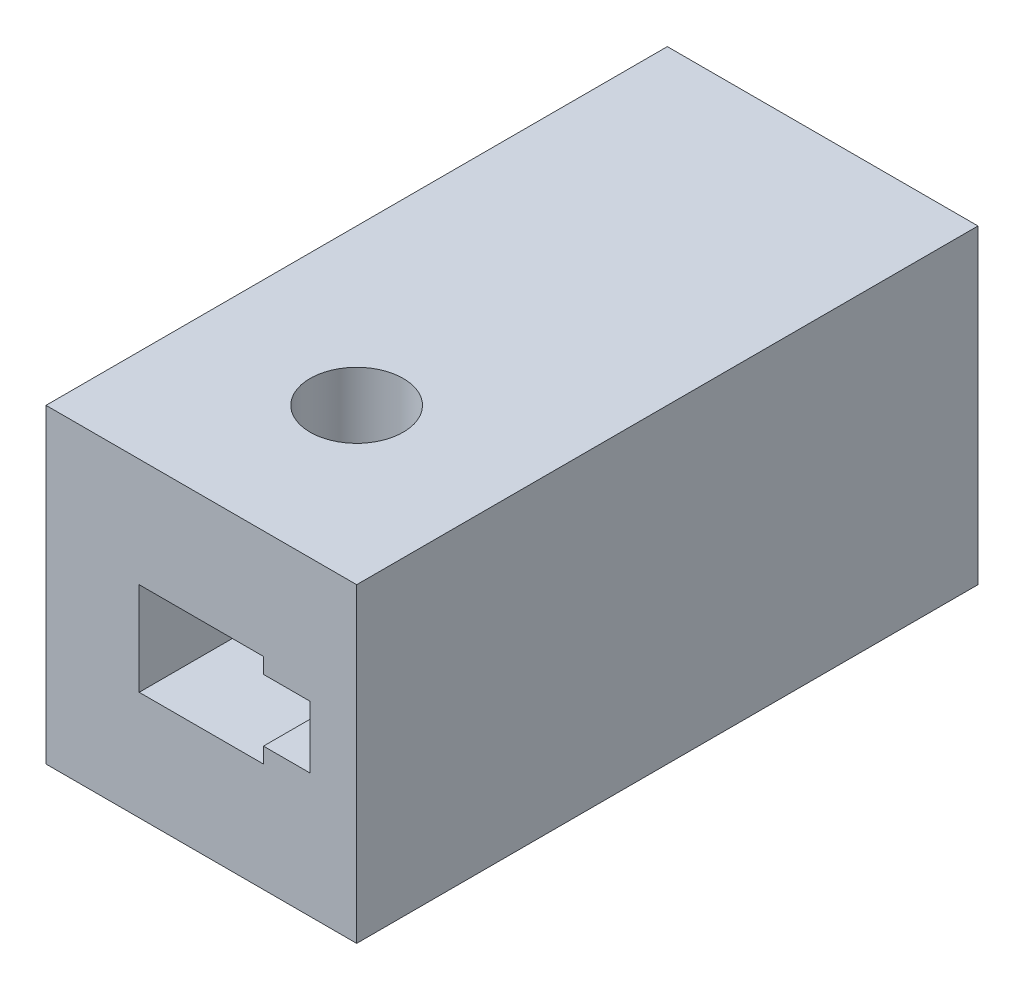
from build123d import *

# Parameters (mm, degrees)
SKETCH1_W           = 10
SKETCH1_H           = 10
BOSS_EXTRUDE1_DEPTH = 20
SKETCH2_R           = 1.5
CUT_EXTRUDE1_DEPTH  = 20


with BuildPart() as part:
    # Sketch1 → Boss-Extrude1 (new body)
    with BuildSketch(Plane.XY):
        Rectangle(SKETCH1_W, SKETCH1_H)
        Polygon((2, -1.5), (-2, -1.5), (-2, 1.5), (2, 1.5), (2, 1), (3.5, 1), (3.5, -1), (2, -1), align=None, mode=Mode.SUBTRACT)
    extrude(amount=BOSS_EXTRUDE1_DEPTH)

    # Sketch2 → Cut-Extrude1 (cut)
    with BuildSketch(Plane.XZ.offset(5)):
        with Locations((0, 15)):
            Circle(SKETCH2_R)
    extrude(amount=-CUT_EXTRUDE1_DEPTH, mode=Mode.SUBTRACT)


solid = part.part
